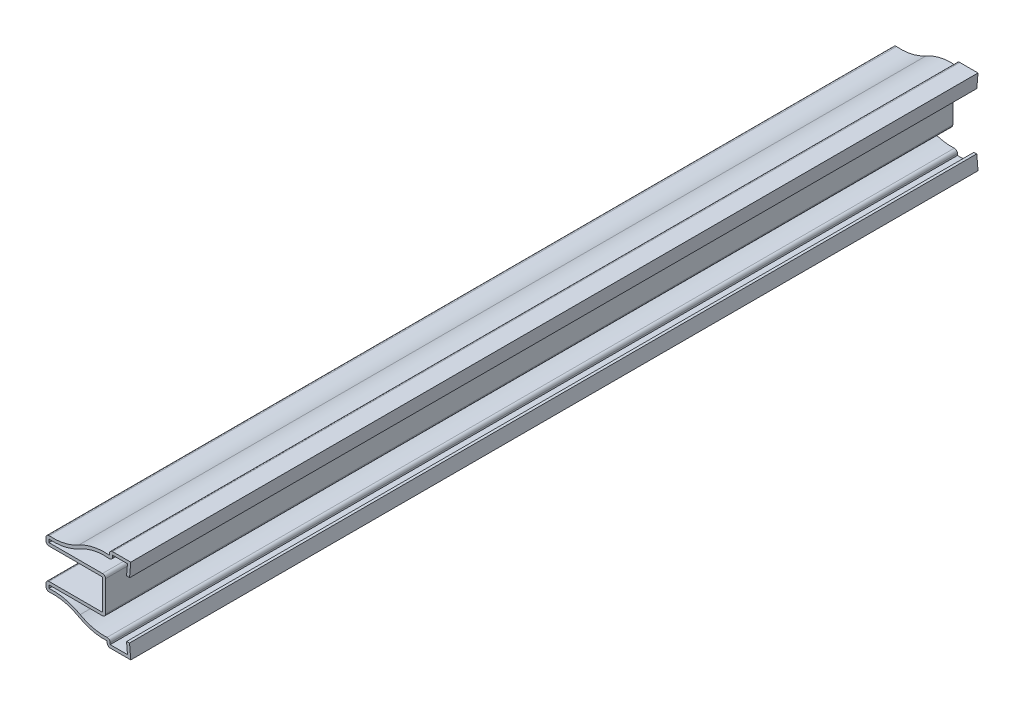
from build123d import *

# Parameters (mm, degrees)
EXTRUDE_THIN1_DEPTH = 285.75
FILLET1_R           = 1.016


with BuildPart() as part:
    # Sketch1 → Extrude-Thin1 (new body)
    with BuildSketch(Plane.XY):
        with BuildLine():
            Line((-0.396875, -9.555854473), (0, -14.318354473))
            Line((0, -14.318354473), (-7.9375, -14.318354473))
            Line((-7.9375, -14.318354473), (-7.9375, -12.730854473))
            ThreePointArc((-7.9375, -12.730854473), (-12.904112533, -12.290327979), (-17.543767938, -10.46415675))
            ThreePointArc((-17.543767938, -10.46415675), (-22.883426301, -8.487890863), (-28.575, -8.334375))
            Line((-28.575, -8.334375), (-28.575, -5.159375))
            Line((-28.575, -5.159375), (-9.525, -5.159375))
            Line((-9.525, -5.159375), (-9.525, 5.159375))
            Line((-9.525, 5.159375), (-28.575, 5.159375))
            Line((-28.575, 5.159375), (-28.575, 8.334375))
            ThreePointArc((-28.575, 8.334375), (-22.883426301, 8.487890863), (-17.543767938, 10.46415675))
            ThreePointArc((-17.543767938, 10.46415675), (-12.515637367, 12.377330284), (-7.14375, 12.669145527))
            Line((-7.14375, 12.669145527), (-7.14375, 14.256645527))
            Line((-7.14375, 14.256645527), (0, 14.256645527))
            Line((0, 14.256645527), (-0.396875, 9.494145527))
            Line((-0.396875, 9.494145527), (-1.40936549, 9.578519735))
            Line((-1.40936549, 9.578519735), (-1.104188341, 13.240645527))
            Line((-1.104188341, 13.240645527), (-6.12775, 13.240645527))
            Line((-6.12775, 13.240645527), (-6.12775, 11.50678851))
            ThreePointArc((-6.12775, 11.50678851), (-11.751151598, 11.490941353), (-17.040496255, 9.581561932))
            ThreePointArc((-17.040496255, 9.581561932), (-22.1225879, 7.60931063), (-27.559, 7.205758691))
            Line((-27.559, 7.205758691), (-27.559, 6.175375))
            Line((-27.559, 6.175375), (-8.509, 6.175375))
            Line((-8.509, 6.175375), (-8.509, -6.175375))
            Line((-8.509, -6.175375), (-27.559, -6.175375))
            Line((-27.559, -6.175375), (-27.559, -7.205758691))
            ThreePointArc((-27.559, -7.205758691), (-22.1225879, -7.60931063), (-17.040496255, -9.581561932))
            ThreePointArc((-17.040496255, -9.581561932), (-12.145263139, -11.416445859), (-6.9215, -11.622370501))
            Line((-6.9215, -11.622370501), (-6.9215, -13.302354473))
            Line((-6.9215, -13.302354473), (-1.104188341, -13.302354473))
            Line((-1.104188341, -13.302354473), (-1.40936549, -9.64022868))
            Line((-1.40936549, -9.64022868), (-0.396875, -9.555854473))
        make_face()
    extrude(amount=-EXTRUDE_THIN1_DEPTH)

    # Fillet1
    fillet1_edges = [part.edges().sort_by_distance(p)[0] for p in [
        (-7.9375, -14.318354473, -142.875),
        (-28.575, -8.334375, -142.875),
        (-28.575, -5.159375, -142.875),
        (-28.575, 5.159375, -142.875),
        (-28.575, 8.334375, -142.875),
        (-7.14375, 14.256645527, -142.875),
        (-6.12775, 11.50678851, -142.875),
        (-8.509, 6.175375, -142.875),
        (-8.509, -6.175375, -142.875),
        (-6.9215, -11.622370501, -142.875),
    ]]
    fillet(fillet1_edges, radius=FILLET1_R)


solid = part.part
